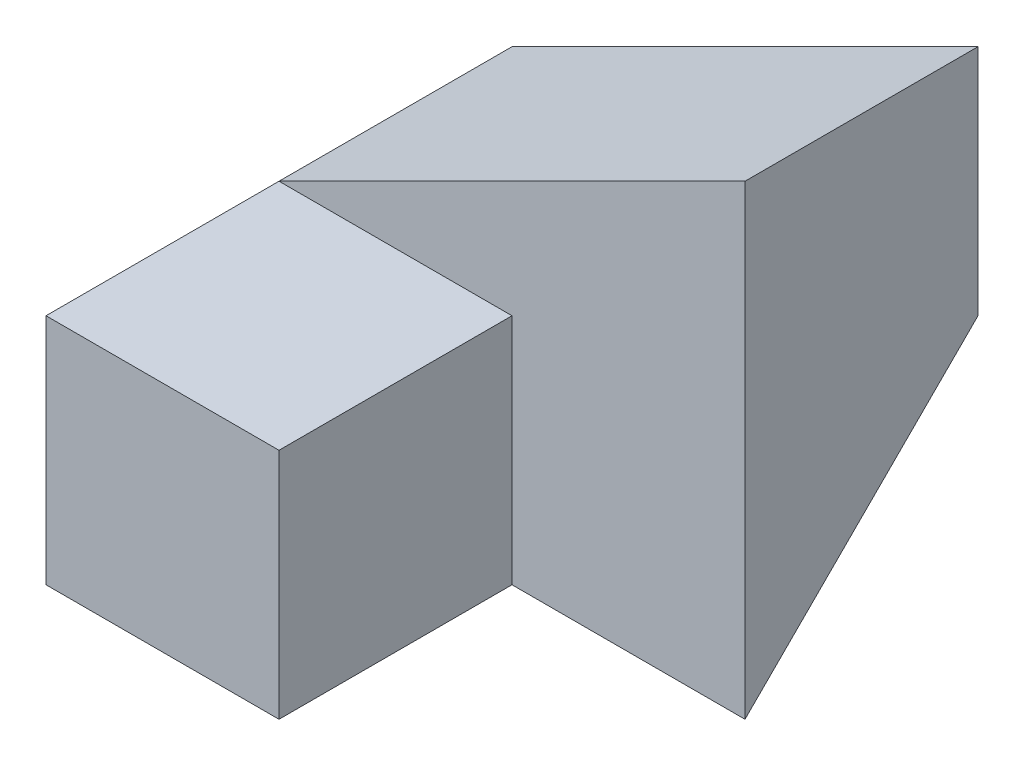
from build123d import *

# Parameters (mm, degrees)
SKETCH1_W           = 40
SKETCH1_H           = 40
BOSS_EXTRUDE1_DEPTH = 40
CUT_EXTRUDE1_DEPTH  = 40
SKETCH3_W           = 20
SKETCH3_H           = 20
CUT_EXTRUDE2_DEPTH  = 40
SKETCH5_W           = 20
SKETCH5_H           = 20
CUT_EXTRUDE4_DEPTH  = 40
CUT_EXTRUDE5_DEPTH  = 40


with BuildPart() as part:
    # Sketch1 → Boss-Extrude1 (new body)
    with BuildSketch(Plane.XY):
        with Locations((20, 20)):
            Rectangle(SKETCH1_W, SKETCH1_H)
    extrude(amount=BOSS_EXTRUDE1_DEPTH)

    # Sketch2 → Cut-Extrude1 (cut)
    with BuildSketch(Plane.XY.offset(40)):
        Polygon((40, 40), (0, 20), (0, 40), align=None)
    extrude(amount=-CUT_EXTRUDE1_DEPTH, mode=Mode.SUBTRACT)

    # Sketch3 → Cut-Extrude2 (cut)
    with BuildSketch(Plane(origin=(40, 0, 0), x_dir=(0, 0, -1), z_dir=(1, 0, 0))):
        with Locations((-30, 30)):
            Rectangle(SKETCH3_W, SKETCH3_H)
    extrude(amount=-CUT_EXTRUDE2_DEPTH, mode=Mode.SUBTRACT)

    # Sketch5 → Cut-Extrude4 (cut)
    with BuildSketch(Plane(origin=(0, 20, 0), x_dir=(1, 0, 0), z_dir=(0, 1, 0))):
        with Locations((30, -30)):
            Rectangle(SKETCH5_W, SKETCH5_H)
    extrude(amount=-CUT_EXTRUDE4_DEPTH, mode=Mode.SUBTRACT)

    # Sketch6 → Cut-Extrude5 (cut)
    with BuildSketch(Plane.ZY):
        Polygon((0, 20), (20, 0), (0, 0), align=None)
    extrude(amount=-CUT_EXTRUDE5_DEPTH, mode=Mode.SUBTRACT)


solid = part.part
